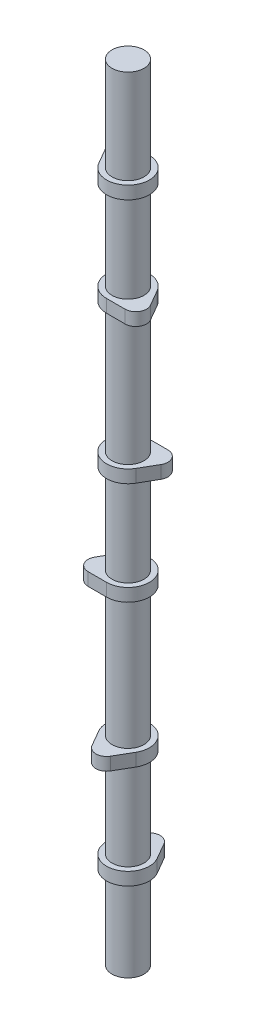
from build123d import *

# Parameters (mm, degrees)
BOSS_EXTRUDE1_DEPTH   = 3.81
BODY_MOVE_COPY2_ANGLE = 180
BOSS_EXTRUDE2_START   = -25.4
SKETCH2_R             = 9.5
BOSS_EXTRUDE2_DEPTH   = 146.05
LPATTERN1_COUNT       = 3
LPATTERN1_PITCH       = 146.05
BODY_MOVE_COPY3_ANGLE = 120
BODY_MOVE_COPY4_ANGLE = 120
SKETCH3_R             = 9.5
BOSS_EXTRUDE3_DEPTH   = 27.94


with BuildPart() as part:
    # Sketch1 → Boss-Extrude1 (new body, symmetric)
    with BuildSketch(Plane(origin=(0, 0, 0), x_dir=(1, 0, 0), z_dir=(0, 1, 0))):
        with BuildLine():
            Line((-5.499261314, 15.875), (-10.998522628, 6.35))
            ThreePointArc((-10.998522628, 6.35), (0, -12.7), (10.998522628, 6.35))
            Line((10.998522628, 6.35), (5.499261314, 15.875))
            ThreePointArc((5.499261314, 15.875), (0, 19.05), (-5.499261314, 15.875))
        make_face()
    extrude(amount=BOSS_EXTRUDE1_DEPTH, both=True)


with BuildPart() as body_2:
    # Body-Move_Copy1: copy of part
    add(part.part.moved(Location((0, 60.96, 0))))


with BuildPart() as body_2_1:
    # Body-Move_Copy2: moved
    add(body_2.part.rotate(Axis((0, 0, 0), (0, 1, 0)), BODY_MOVE_COPY2_ANGLE))


with BuildPart() as part_1:
    add(part.part)

    add(body_2_1.part)  # Boss-Extrude2 merges body 2
    # Sketch2 → Boss-Extrude2 (add)
    with BuildSketch(Plane(origin=(0, 0, 0), x_dir=(1, 0, 0), z_dir=(0, 1, 0)).offset(BOSS_EXTRUDE2_START)):
        Circle(SKETCH2_R)
    extrude(amount=BOSS_EXTRUDE2_DEPTH)


with BuildPart() as lpattern1_1:
    # LPattern1: pattern copy
    add(part_1.part.moved(Location(Vector(0, 1, 0) * (1 * LPATTERN1_PITCH))))


with BuildPart() as lpattern1_2:
    # LPattern1: pattern copy
    add(part_1.part.moved(Location(Vector(0, 1, 0) * (2 * LPATTERN1_PITCH))))


with BuildPart() as lpattern1_1_1:
    # Body-Move_Copy3: moved
    add(lpattern1_1.part.rotate(Axis((0, 0, 0), (0, 1, 0)), BODY_MOVE_COPY3_ANGLE))


with BuildPart() as lpattern1_2_1:
    # Body-Move_Copy4: moved
    add(lpattern1_2.part.rotate(Axis((0, 0, 0), (0, -1, 0)), BODY_MOVE_COPY4_ANGLE))


with BuildPart() as part_2:
    add(part_1.part)

    # Sketch3 → Boss-Extrude3 (add)
    with BuildSketch(Plane.XZ.offset(25.4)):
        Circle(SKETCH3_R)
    extrude(amount=BOSS_EXTRUDE3_DEPTH)

    # Combine1: union LPattern1_1, LPattern1_2
    add(lpattern1_1_1.part)
    add(lpattern1_2_1.part)


solid = part_2.part
